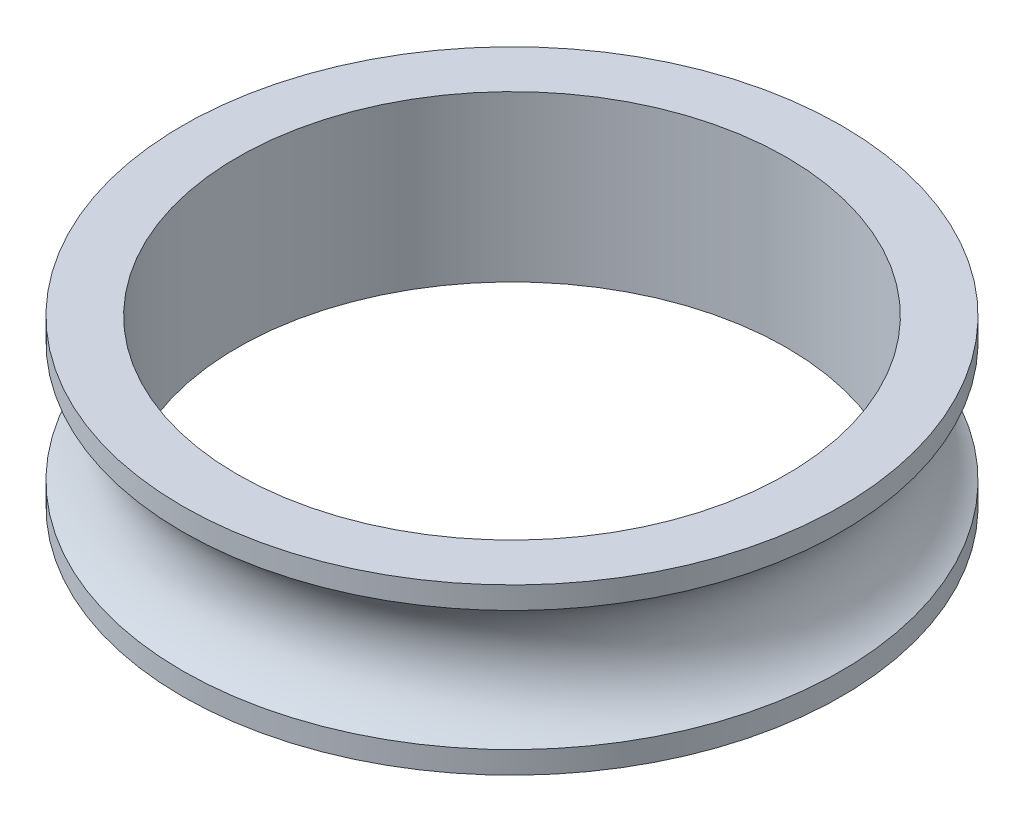
from build123d import *

# Parameters (mm, degrees)
SKETCH1_R           = 12
SKETCH1_R_2         = 10
BOSS_EXTRUDE1_DEPTH = 6
SKETCH4_R           = 2.5


with BuildPart() as part:
    # Sketch1 → Boss-Extrude1 (new body)
    with BuildSketch(Plane(origin=(0, 0, 0), x_dir=(1, 0, 0), z_dir=(0, 1, 0))):
        Circle(SKETCH1_R)
        Circle(SKETCH1_R_2, mode=Mode.SUBTRACT)
    extrude(amount=BOSS_EXTRUDE1_DEPTH)

    # Sketch4 → Cut-Revolve2 (revolve, cut)
    with BuildSketch(Plane(origin=(0, 0, 0), x_dir=(0, 0, -1), z_dir=(1, 0, 0))):
        with Locations((-13.2, 3)):
            Circle(SKETCH4_R)
    revolve(axis=Axis((0, 0, 0), (0, 1, 0)), mode=Mode.SUBTRACT)


solid = part.part
